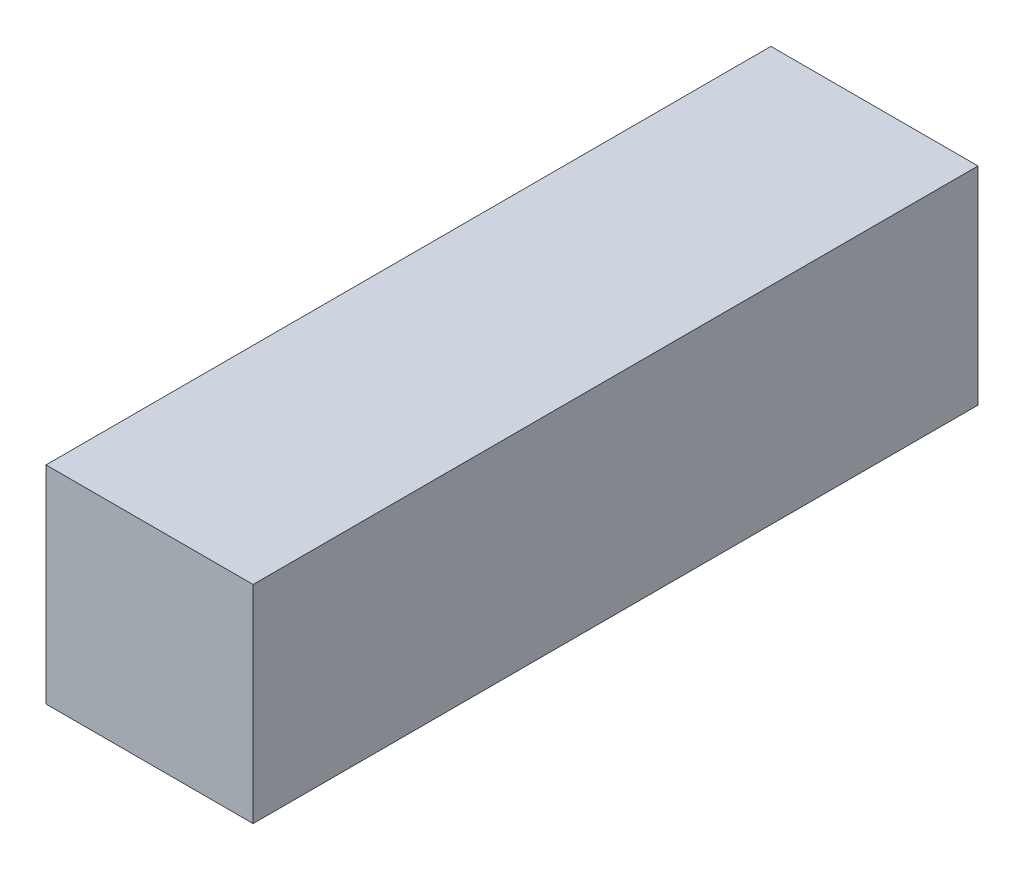
from build123d import *

# Parameters (mm, degrees)
SKETCH_1_W      = 8
SKETCH_1_H      = 8
EXTRUDE_1_DEPTH = 28


with BuildPart() as part:
    # Эскиз1 → Бобышка-Вытянуть1 (new body)
    with BuildSketch(Plane.XY):
        with Locations((0, 12.5)):
            Rectangle(SKETCH_1_W, SKETCH_1_H)
    extrude(amount=-EXTRUDE_1_DEPTH)


solid = part.part
